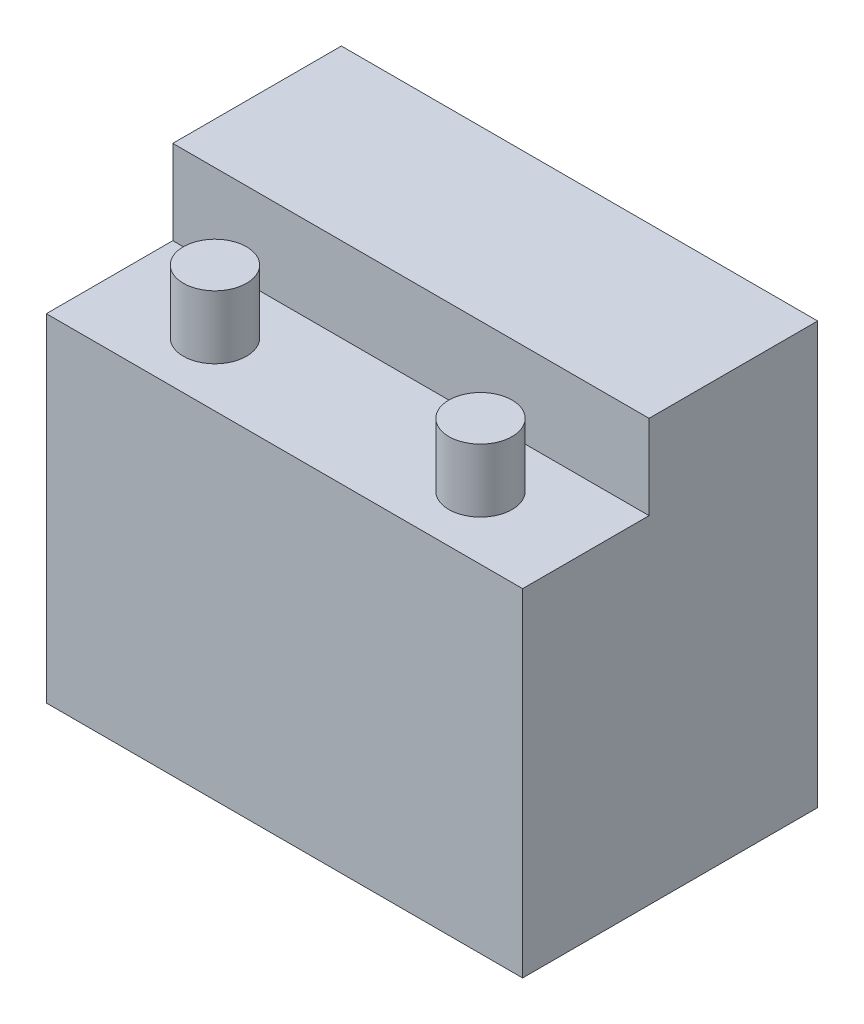
from build123d import *

# Parameters (mm, degrees)
SKETCH1_W           = 113
SKETCH1_H           = 70
BOSS_EXTRUDE1_DEPTH = 100
SKETCH2_W           = 113
SKETCH2_H           = 30
CUT_EXTRUDE2_DEPTH  = 20
SKETCH3_R           = 7.5
BOSS_EXTRUDE2_DEPTH = 15


with BuildPart() as part:
    # Sketch1 → Boss-Extrude1 (new body)
    with BuildSketch(Plane(origin=(0, 0, 0), x_dir=(1, 0, 0), z_dir=(0, 1, 0))):
        Rectangle(SKETCH1_W, SKETCH1_H)
    extrude(amount=BOSS_EXTRUDE1_DEPTH)

    # Sketch2 → Cut-Extrude2 (cut)
    with BuildSketch(Plane(origin=(0, 100, 0), x_dir=(1, 0, 0), z_dir=(0, 1, 0))):
        with Locations((0, -20)):
            Rectangle(SKETCH2_W, SKETCH2_H)
    extrude(amount=-CUT_EXTRUDE2_DEPTH, mode=Mode.SUBTRACT)

    # Sketch3 → Boss-Extrude2 (add)
    with BuildSketch(Plane(origin=(0, 80, 0), x_dir=(1, 0, 0), z_dir=(0, 1, 0))):
        with Locations((-31.5, -20)):
            Circle(SKETCH3_R)
        with Locations((31.5, -20)):
            Circle(SKETCH3_R)
    extrude(amount=BOSS_EXTRUDE2_DEPTH)


solid = part.part
